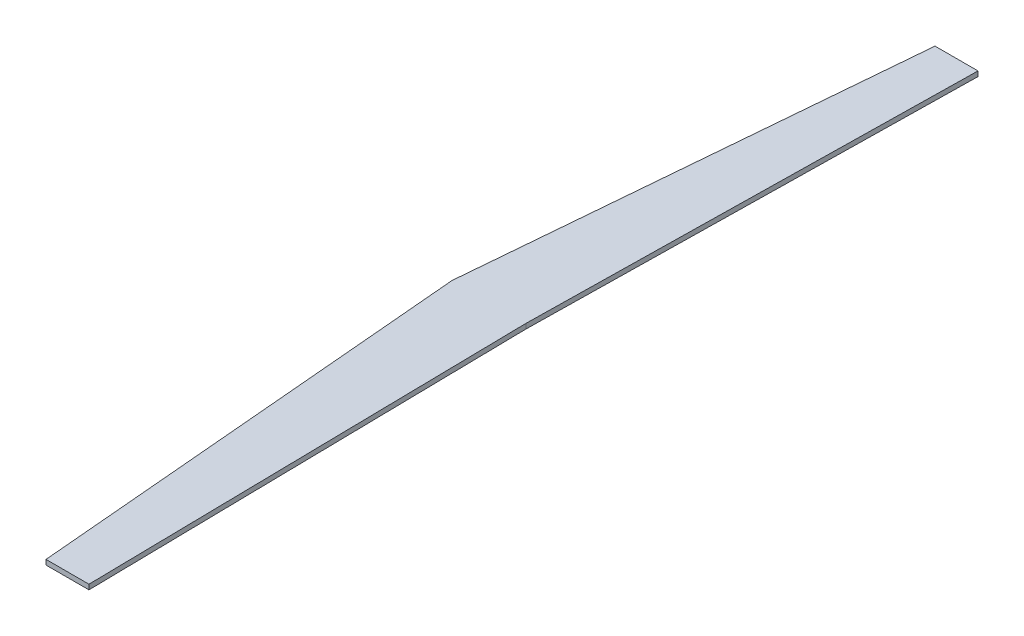
from build123d import *

# Parameters (mm, degrees)
BOSS_EXTRUDE1_DEPTH = 3


with BuildPart() as part:
    # Sketch1 → Boss-Extrude1 (new body)
    with BuildSketch(Plane(origin=(0, 0, 0), x_dir=(1, 0, 0), z_dir=(0, 1, 0))):
        Polygon((49.5, 270), (23.4, 270), (0, 0), (23.4, -270), (49.5, -270), (45, 0), align=None)
    extrude(amount=BOSS_EXTRUDE1_DEPTH)


solid = part.part
